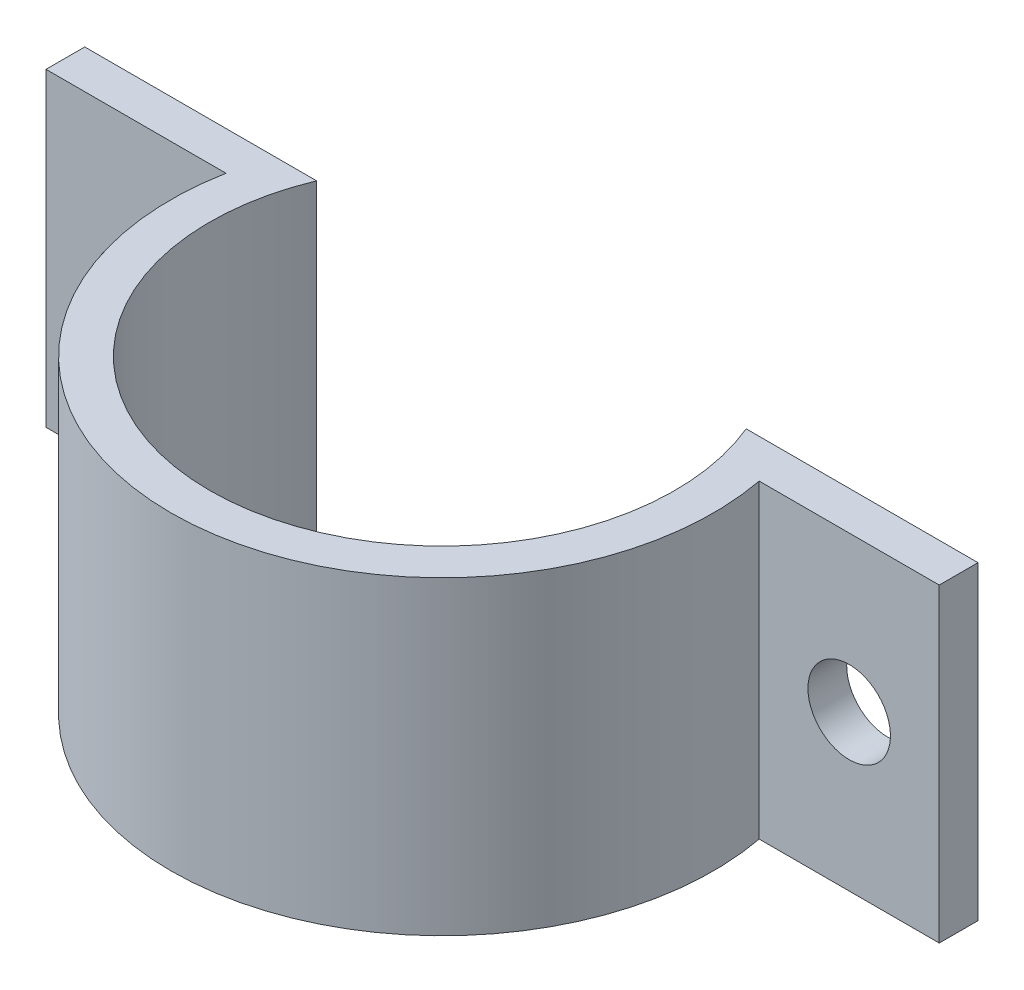
from build123d import *

# Parameters (mm, degrees)
SKETCH1_R           = 19.05
BOSS_EXTRUDE1_DEPTH = 25.4
SKETCH2_R           = 3.3782
CUT_EXTRUDE1_DEPTH  = 36.8775
SKETCH3_W           = 84.126846883
SKETCH3_H           = 24.140829336
CUT_EXTRUDE2_DEPTH  = 26.4


with BuildPart() as part:
    # Sketch1 → Boss-Extrude1 (new body)
    with BuildSketch(Plane(origin=(0, 0, 0), x_dir=(1, 0, 0), z_dir=(0, 1, 0))):
        with BuildLine():
            Line((36.587384889, 13.6525), (17.537384889, 13.6525))
            ThreePointArc((17.537384889, 13.6525), (0, 22.225), (-17.537384889, 13.6525))
            Line((-17.537384889, 13.6525), (-36.587384889, 13.6525))
            Line((-36.587384889, 13.6525), (-36.587384889, 4.1275))
            Line((-36.587384889, 4.1275), (-21.838369187, 4.1275))
            ThreePointArc((-21.838369187, 4.1275), (0, -22.225), (21.838369187, 4.1275))
            Line((21.838369187, 4.1275), (36.587384889, 4.1275))
            Line((36.587384889, 4.1275), (36.587384889, 13.6525))
        make_face()
        Circle(SKETCH1_R, mode=Mode.SUBTRACT)
    extrude(amount=BOSS_EXTRUDE1_DEPTH)

    # Sketch2 → Cut-Extrude1 (cut, through all)
    with BuildSketch(Plane(origin=(0, 0, -13.6525), x_dir=(-1, 0, 0), z_dir=(0, 0, -1))):
        with Locations((29.21, 12.7)):
            Circle(SKETCH2_R)
        with Locations((-29.21, 12.7)):
            Circle(SKETCH2_R)
    extrude(amount=-CUT_EXTRUDE1_DEPTH, mode=Mode.SUBTRACT)

    # Sketch3 → Cut-Extrude2 (cut, through all)
    with BuildSketch(Plane(origin=(0, 25.4, 0), x_dir=(1, 0, 0), z_dir=(0, 1, 0))):
        with Locations((0.41143502, 19.372914668)):
            Rectangle(SKETCH3_W, SKETCH3_H)
    extrude(amount=-CUT_EXTRUDE2_DEPTH, mode=Mode.SUBTRACT)


solid = part.part
